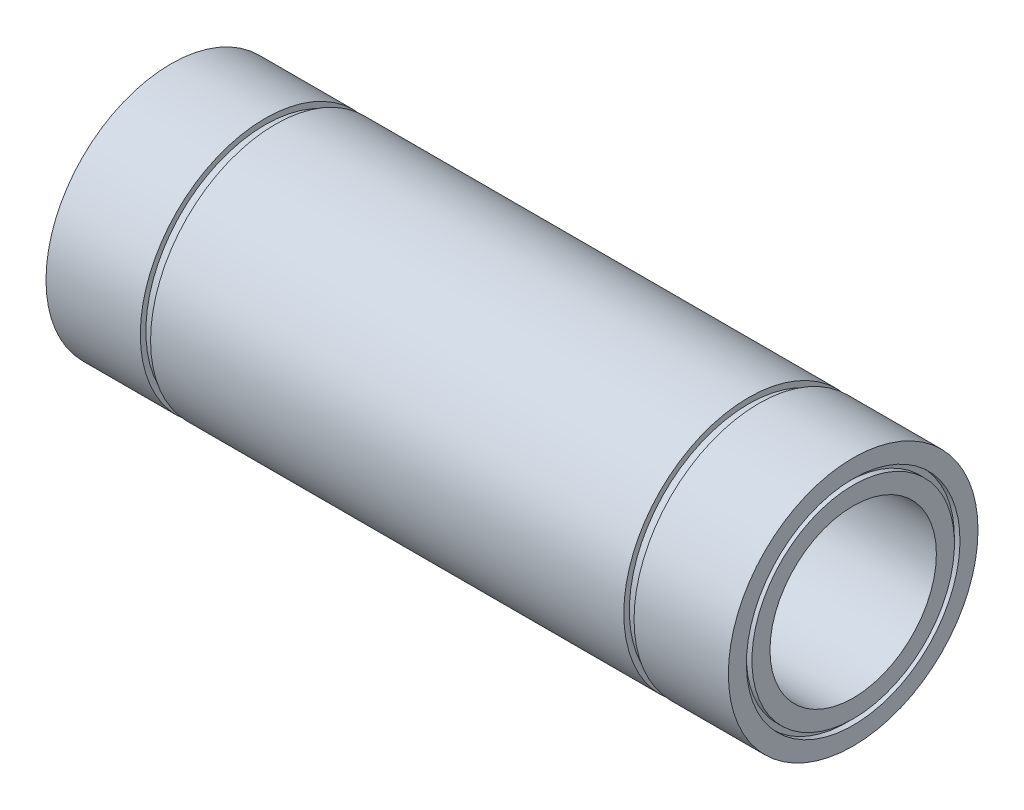
from build123d import *


with BuildPart() as part:
    # Esboço1 → Revolução1 (revolve)
    with BuildSketch(Plane.XY):
        Polygon((-61.5, 22.5), (-44.5, 22.5), (-44.5, 21.5), (-42.65, 21.5), (-42.65, 22.5), (42.65, 22.5), (42.65, 21.5), (44.5, 21.5), (44.5, 22.5), (61.5, 22.5), (61.5, 19.25), (60.5, 19.25), (60.5, 18.25), (61.5, 18.25), (61.5, 15), (-61.5, 15), (-61.5, 18.25), (-60.5, 18.25), (-60.5, 19.25), (-61.5, 19.25), align=None)
    revolve(axis=Axis((0, 0, 0), (-1, 0, 0)))


solid = part.part
